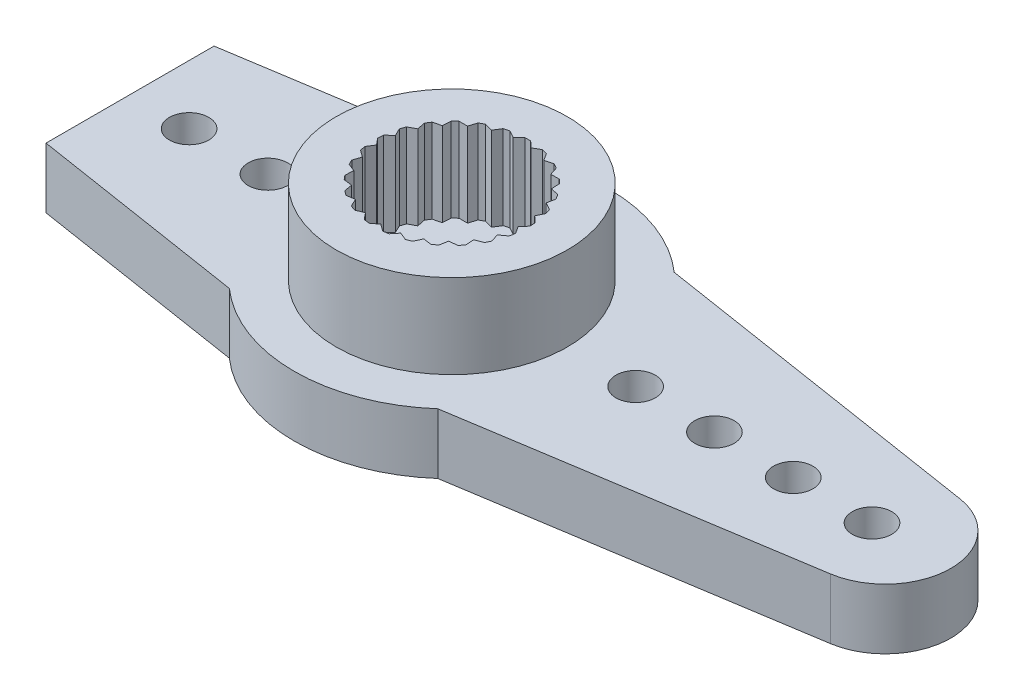
from build123d import *

# Parameters (mm, degrees)
SKETCH2_R           = 6
SKETCH2_R_2         = 1.5
BOSS_EXTRUDE1_DEPTH = 1.15
SKETCH3_R           = 4.4
BOSS_EXTRUDE2_DEPTH = 3.2
SKETCH4_R           = 0.75
BOSS_EXTRUDE3_DEPTH = 1.15
CIRPATTERN1_COUNT   = 2
CUT_EXTRUDE1_DEPTH  = 10


with BuildPart() as part:
    # Sketch2 → Boss-Extrude1 (new, symmetric)
    with BuildSketch(Plane(origin=(0, 0, 0), x_dir=(1, 0, 0), z_dir=(0, 1, 0))):
        with Locations(Location((0, 0, 0), (0, 0, 270))):
            Circle(SKETCH2_R)
        with Locations(Location((0, 0, 0), (0, 0, 270))):
            Circle(SKETCH2_R_2, mode=Mode.SUBTRACT)
    extrude(amount=BOSS_EXTRUDE1_DEPTH, both=True)

    # Sketch3 → Boss-Extrude2 (add)
    with BuildSketch(Plane(origin=(0, 1.15, 0), x_dir=(1, 0, 0), z_dir=(0, 1, 0))):
        with Locations(Location((0, 0, 0), (0, 0, 270))):
            Circle(SKETCH3_R)
        with BuildLine():
            Line((0.107421435, 2.898009771), (0.338399731, 2.678709694))
            Line((0.338399731, 2.678709694), (0.61665913, 2.83367809))
            ThreePointArc((0.61665913, 2.83367809), (0.721200673, 2.808891167), (0.824752316, 2.780248841))
            Line((0.824752316, 2.780248841), (0.993936292, 2.510396512))
            Line((0.993936292, 2.510396512), (1.301992734, 2.591295993))
            ThreePointArc((1.301992734, 2.591295993), (1.397085655, 2.541289372), (1.490260976, 2.48779465))
            Line((1.490260976, 2.48779465), (1.587020181, 2.184345885))
            Line((1.587020181, 2.184345885), (1.905517346, 2.186093238))
            ThreePointArc((1.905517346, 2.186093238), (1.985186607, 2.11400902), (2.062131058, 2.039023173))
            Line((2.062131058, 2.039023173), (2.080385755, 1.721044772))
            Line((2.080385755, 1.721044772), (2.389311295, 1.643530205))
            ThreePointArc((2.389311295, 1.643530205), (2.448550984, 1.553897705), (2.504429862, 1.46213237))
            Line((2.504429862, 1.46213237), (2.443033042, 1.149604087))
            Line((2.443033042, 1.149604087), (2.722976028, 0.997698125))
            ThreePointArc((2.722976028, 0.997698125), (2.758063897, 0.896149284), (2.789366126, 0.793370413))
            Line((2.789366126, 0.793370413), (2.652175577, 0.505929549))
            Line((2.652175577, 0.505929549), (2.885546163, 0.289177003))
            ThreePointArc((2.885546163, 0.289177003), (2.894277512, 0.182092507), (2.899036259, 0.074758075))
            Line((2.899036259, 0.074758075), (2.694672167, -0.169534403))
            Line((2.694672167, -0.169534403), (2.866806821, -0.437514174))
            ThreePointArc((2.866806821, -0.437514174), (2.848633027, -0.543405812), (2.826549281, -0.648551587))
            Line((2.826549281, -0.648551587), (2.567852594, -0.834345885))
            Line((2.567852594, -0.834345885), (2.667935462, -1.136714727))
            ThreePointArc((2.667935462, -1.136714727), (2.623998452, -1.234759946), (2.576459817, -1.331110368))
            Line((2.576459817, -1.331110368), (2.279685399, -1.446732346))
            Line((2.279685399, -1.446732346), (2.301427906, -1.764491312))
            ThreePointArc((2.301427906, -1.764491312), (2.234488404, -1.84852957), (2.164481907, -1.930030589))
            Line((2.164481907, -1.930030589), (1.848277186, -1.968215294))
            Line((1.848277186, -1.968215294), (1.790313171, -2.281398419))
            ThreePointArc((1.790313171, -2.281398419), (1.704577232, -2.346149284), (1.616501638, -2.40767989))
            Line((1.616501638, -2.40767989), (1.30073492, -2.366028036))
            Line((1.30073492, -2.366028036), (1.166706475, -2.654956874))
            ThreePointArc((1.166706475, -2.654956874), (1.067561203, -2.696351809), (0.966950626, -2.734045809))
            Line((0.966950626, -2.734045809), (0.671462695, -2.615174535))
            Line((0.671462695, -2.615174535), (0.469791321, -2.861694623))
            ThreePointArc((0.469791321, -2.861694623), (0.363466377, -2.877132634), (0.25664255, -2.888621575))
            Line((0.25664255, -2.888621575), (0, -2.7))
            Line((0, -2.7), (-0.25664255, -2.888621575))
            ThreePointArc((-0.25664255, -2.888621575), (-0.363466377, -2.877132634), (-0.469791321, -2.861694623))
            Line((-0.469791321, -2.861694623), (-0.671462695, -2.615174535))
            Line((-0.671462695, -2.615174535), (-0.966950626, -2.734045809))
            ThreePointArc((-0.966950626, -2.734045809), (-1.067561203, -2.696351809), (-1.166706475, -2.654956874))
            Line((-1.166706475, -2.654956874), (-1.30073492, -2.366028036))
            Line((-1.30073492, -2.366028036), (-1.616501638, -2.40767989))
            ThreePointArc((-1.616501638, -2.40767989), (-1.704577232, -2.346149284), (-1.790313171, -2.281398419))
            Line((-1.790313171, -2.281398419), (-1.848277186, -1.968215294))
            Line((-1.848277186, -1.968215294), (-2.164481907, -1.930030589))
            ThreePointArc((-2.164481907, -1.930030589), (-2.234488404, -1.84852957), (-2.301427906, -1.764491312))
            Line((-2.301427906, -1.764491312), (-2.279685399, -1.446732346))
            Line((-2.279685399, -1.446732346), (-2.576459817, -1.331110368))
            ThreePointArc((-2.576459817, -1.331110368), (-2.623998452, -1.234759946), (-2.667935462, -1.136714727))
            Line((-2.667935462, -1.136714727), (-2.567852594, -0.834345885))
            Line((-2.567852594, -0.834345885), (-2.826549281, -0.648551587))
            ThreePointArc((-2.826549281, -0.648551587), (-2.848633027, -0.543405812), (-2.866806821, -0.437514174))
            Line((-2.866806821, -0.437514174), (-2.694672167, -0.169534403))
            Line((-2.694672167, -0.169534403), (-2.899036259, 0.074758075))
            ThreePointArc((-2.899036259, 0.074758075), (-2.894277512, 0.182092507), (-2.885546163, 0.289177003))
            Line((-2.885546163, 0.289177003), (-2.652175577, 0.505929549))
            Line((-2.652175577, 0.505929549), (-2.789366126, 0.793370413))
            ThreePointArc((-2.789366126, 0.793370413), (-2.758063897, 0.896149284), (-2.722976028, 0.997698125))
            Line((-2.722976028, 0.997698125), (-2.443033042, 1.149604087))
            Line((-2.443033042, 1.149604087), (-2.504429862, 1.46213237))
            ThreePointArc((-2.504429862, 1.46213237), (-2.448550984, 1.553897705), (-2.389311295, 1.643530205))
            Line((-2.389311295, 1.643530205), (-2.080385755, 1.721044772))
            Line((-2.080385755, 1.721044772), (-2.062131058, 2.039023173))
            ThreePointArc((-2.062131058, 2.039023173), (-1.985186607, 2.11400902), (-1.905517346, 2.186093238))
            Line((-1.905517346, 2.186093238), (-1.587020181, 2.184345885))
            Line((-1.587020181, 2.184345885), (-1.490260976, 2.48779465))
            ThreePointArc((-1.490260976, 2.48779465), (-1.397085655, 2.541289372), (-1.301992734, 2.591295993))
            Line((-1.301992734, 2.591295993), (-0.993936292, 2.510396512))
            Line((-0.993936292, 2.510396512), (-0.824752316, 2.780248841))
            ThreePointArc((-0.824752316, 2.780248841), (-0.721200673, 2.808891167), (-0.61665913, 2.83367809))
            Line((-0.61665913, 2.83367809), (-0.338399731, 2.678709694))
            Line((-0.338399731, 2.678709694), (-0.107421435, 2.898009771))
            ThreePointArc((-0.107421435, 2.898009771), (0, 2.9), (0.107421435, 2.898009771))
        make_face(mode=Mode.SUBTRACT)
    extrude(amount=BOSS_EXTRUDE2_DEPTH)

    # Sketch4 → Boss-Extrude3 (add, symmetric)
    with BuildSketch(Plane(origin=(0, 0, 0), x_dir=(1, 0, 0), z_dir=(0, 1, 0))):
        with BuildLine():
            Line((3.968626967, 4.5), (16.888114198, 2.469689731))
            ThreePointArc((16.888114198, 2.469689731), (19, 0), (16.888114198, -2.469689731))
            Line((16.888114198, -2.469689731), (3.968626967, -4.5))
            ThreePointArc((3.968626967, -4.5), (6, 0), (3.968626967, 4.5))
        make_face()
        with Locations(Location((16, 0, 0), (0, 0, 270))):
            Circle(SKETCH4_R, mode=Mode.SUBTRACT)
        with Locations(Location((13, 0, 0), (0, 0, 270))):
            Circle(SKETCH4_R, mode=Mode.SUBTRACT)
        with Locations(Location((10, 0, 0), (0, 0, 270))):
            Circle(SKETCH4_R, mode=Mode.SUBTRACT)
        with Locations(Location((7, 0, 0), (0, 0, 270))):
            Circle(SKETCH4_R, mode=Mode.SUBTRACT)
    boss_extrude3 = extrude(amount=BOSS_EXTRUDE3_DEPTH, both=True)

    # CirPattern1: Boss-Extrude3 ×2 about axis
    cirpattern1_axis = Axis((0, 0, 0), (0, 1, 0))
    for i in range(1, CIRPATTERN1_COUNT):
        add(boss_extrude3.rotate(cirpattern1_axis, i * 360 / CIRPATTERN1_COUNT))

    # Sketch6 → Cut-Extrude1 (cut)
    with BuildSketch(Plane.XZ.offset(1.15)):
        Polygon((-12.25, 0), (-12.25, 5.932687926), (-21.293207436, 5.932687926), (-21.293207436, 0), (-21.293207436, -7.371619722), (-12.25, -7.371619722), align=None)
    extrude(amount=-CUT_EXTRUDE1_DEPTH, mode=Mode.SUBTRACT)


solid = part.part
